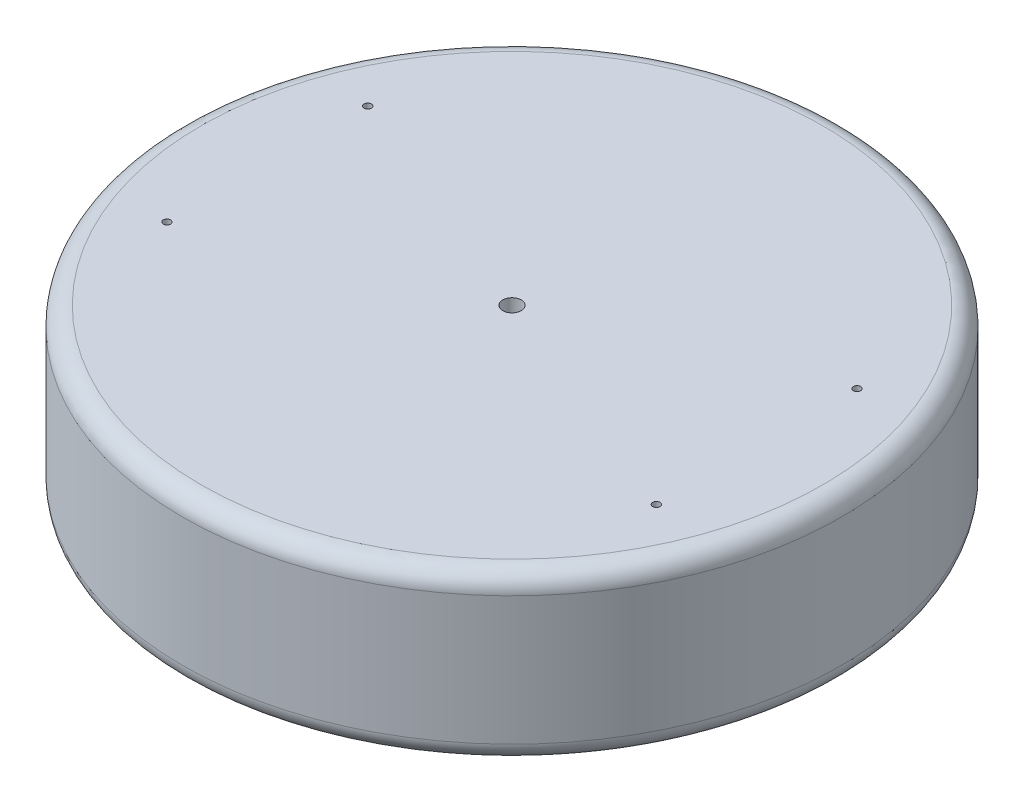
from build123d import *

# Parameters (mm, degrees)
SKETCH1_R           = 177
SKETCH1_R_2         = 5
BOSS_EXTRUDE1_DEPTH = 89
SKETCH2_R           = 1.975
CUT_EXTRUDE1_DEPTH  = 19
FILLET1_R           = 10


with BuildPart() as part:
    # Sketch1 → Boss-Extrude1 (new body)
    with BuildSketch(Plane(origin=(0, 0, 0), x_dir=(1, 0, 0), z_dir=(0, 1, 0))):
        Circle(SKETCH1_R)
        Circle(SKETCH1_R_2, mode=Mode.SUBTRACT)
    extrude(amount=BOSS_EXTRUDE1_DEPTH)

    # Sketch2 → Cut-Extrude1 (cut)
    with BuildSketch(Plane(origin=(0, 89, 0), x_dir=(1, 0, 0), z_dir=(0, 1, 0))):
        with Locations((-131.4, 53.9)):
            Circle(SKETCH2_R)
        with Locations((-131.4, -53.9)):
            Circle(SKETCH2_R)
        with Locations((131.4, -53.9)):
            Circle(SKETCH2_R)
        with Locations((131.4, 53.9)):
            Circle(SKETCH2_R)
    extrude(amount=-CUT_EXTRUDE1_DEPTH, mode=Mode.SUBTRACT)

    # Fillet1
    fillet1_edges = [part.edges().sort_by_distance(p)[0] for p in [
        (-177, 0, 0),
        (-177, 89, 0),
    ]]
    fillet(fillet1_edges, radius=FILLET1_R)


solid = part.part
